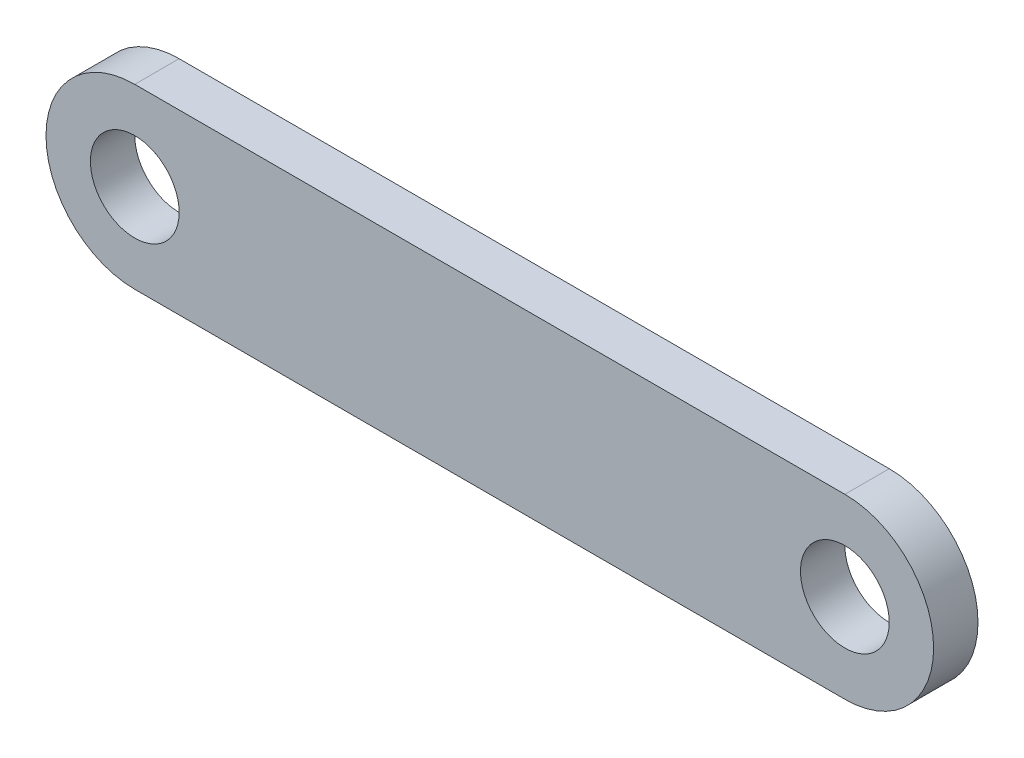
from build123d import *

# Parameters (mm, degrees)
SKETCH1_R           = 2
BOSS_EXTRUDE1_DEPTH = 1


with BuildPart() as part:
    # Sketch1 → Boss-Extrude1 (new body, symmetric)
    with BuildSketch(Plane.XY):
        with BuildLine():
            Line((19.199496106, -4.508474576), (-12.800503894, -4.508474576))
            ThreePointArc((-12.800503894, -4.508474576), (-16.800503894, -0.508474576), (-12.800503894, 3.491525424))
            Line((-12.800503894, 3.491525424), (19.199496106, 3.491525424))
            ThreePointArc((19.199496106, 3.491525424), (23.199496106, -0.508474576), (19.199496106, -4.508474576))
        make_face()
        with Locations((19.199496106, -0.508474576)):
            Circle(SKETCH1_R, mode=Mode.SUBTRACT)
        with Locations((-12.800503894, -0.508474576)):
            Circle(SKETCH1_R, mode=Mode.SUBTRACT)
    extrude(amount=BOSS_EXTRUDE1_DEPTH, both=True)


solid = part.part
